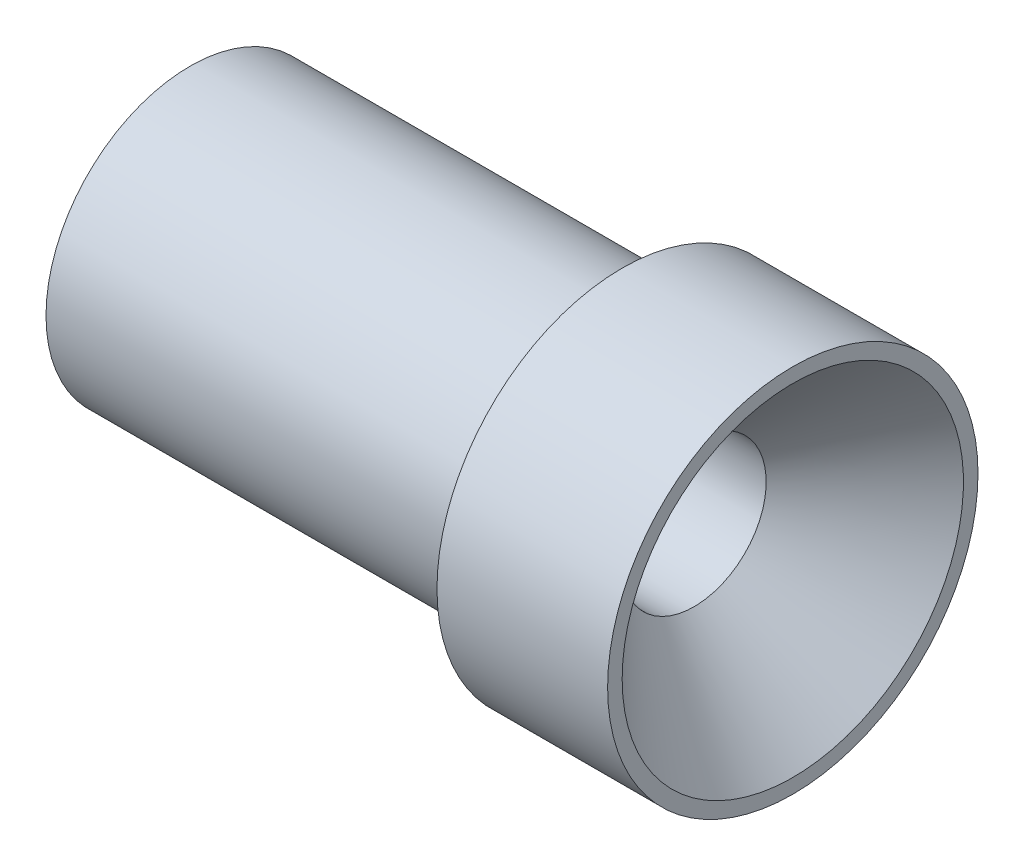
from build123d import *

# Parameters (mm, degrees)
PAH1_SIZE2 = 0.5
PAH1_SIZE  = 0.353553391


with BuildPart() as part:
    # Çizim1 → Döndür1 (revolve)
    with BuildSketch(Plane.XY):
        Polygon((15, 4.5), (10.5, 4.5), (10.5, 3.5), (0, 3.5), (0, 1.75), (12.25, 1.75), align=None)
    revolve(axis=Axis((0, 0, 0), (1, 0, 0)))

    # Pah1
    pah1_edges = [part.edges().sort_by_distance(p)[0] for p in [
        (15, -4.5, 0),
    ]]
    chamfer(pah1_edges, length=PAH1_SIZE, length2=PAH1_SIZE2)


solid = part.part
